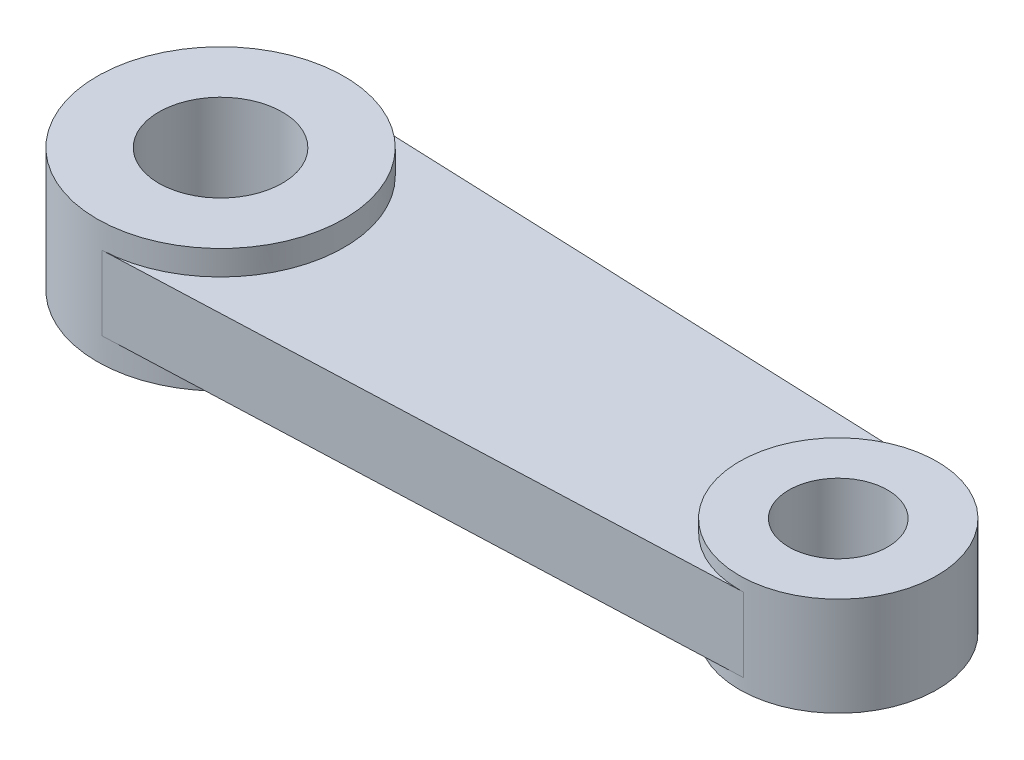
from build123d import *

# Parameters (mm, degrees)
AUFSATZ_LINEAR_AUSTRAGEN1_DEPTH = 3
SKIZZE4_3_R                     = 10
SKIZZE4_3_R_2                   = 5
AUFSATZ_LINEAR_AUSTRAGEN2_DEPTH = 5
SKIZZE4_4_R                     = 8
SKIZZE4_4_R_2                   = 4
AUFSATZ_LINEAR_AUSTRAGEN3_DEPTH = 4


with BuildPart() as part:
    # Skizze4 → Aufsatz-Linear austragen1 (new body, symmetric)
    with BuildSketch(Plane(origin=(0, 0, 0), x_dir=(1, 0, 0), z_dir=(0, 1, 0))):
        with BuildLine():
            Line((50.32, 7.993597438), (0.4, 9.991996797))
            ThreePointArc((0.4, 9.991996797), (7.211102551, 6.92820323), (10, 0))
            ThreePointArc((10, 0), (7.211102551, -6.92820323), (0.4, -9.991996797))
            Line((0.4, -9.991996797), (50.32, -7.993597438))
            ThreePointArc((50.32, -7.993597438), (42, 0), (50.32, 7.993597438))
        make_face()
    extrude(amount=AUFSATZ_LINEAR_AUSTRAGEN1_DEPTH, both=True)

    # Skizze4_3 → Aufsatz-Linear austragen2 (add, symmetric)
    with BuildSketch(Plane(origin=(0, 0, 0), x_dir=(1, 0, 0), z_dir=(0, 1, 0))):
        with Locations(Location((0, 0, 0), (0, 0, 270))):  # turned: the seam where the file's is
            Circle(SKIZZE4_3_R)
        with Locations(Location((0, 0, 0), (0, 0, 270))):  # turned: the seam where the file's is
            Circle(SKIZZE4_3_R_2, mode=Mode.SUBTRACT)
    extrude(amount=AUFSATZ_LINEAR_AUSTRAGEN2_DEPTH, both=True)

    # Skizze4_4 → Aufsatz-Linear austragen3 (add, symmetric)
    with BuildSketch(Plane(origin=(0, 0, 0), x_dir=(1, 0, 0), z_dir=(0, 1, 0))):
        with Locations(Location((50, 0, 0), (0, 0, 270))):  # turned: the seam where the file's is
            Circle(SKIZZE4_4_R)
        with Locations(Location((50, 0, 0), (0, 0, 270))):  # turned: the seam where the file's is
            Circle(SKIZZE4_4_R_2, mode=Mode.SUBTRACT)
    extrude(amount=AUFSATZ_LINEAR_AUSTRAGEN3_DEPTH, both=True)


solid = part.part
